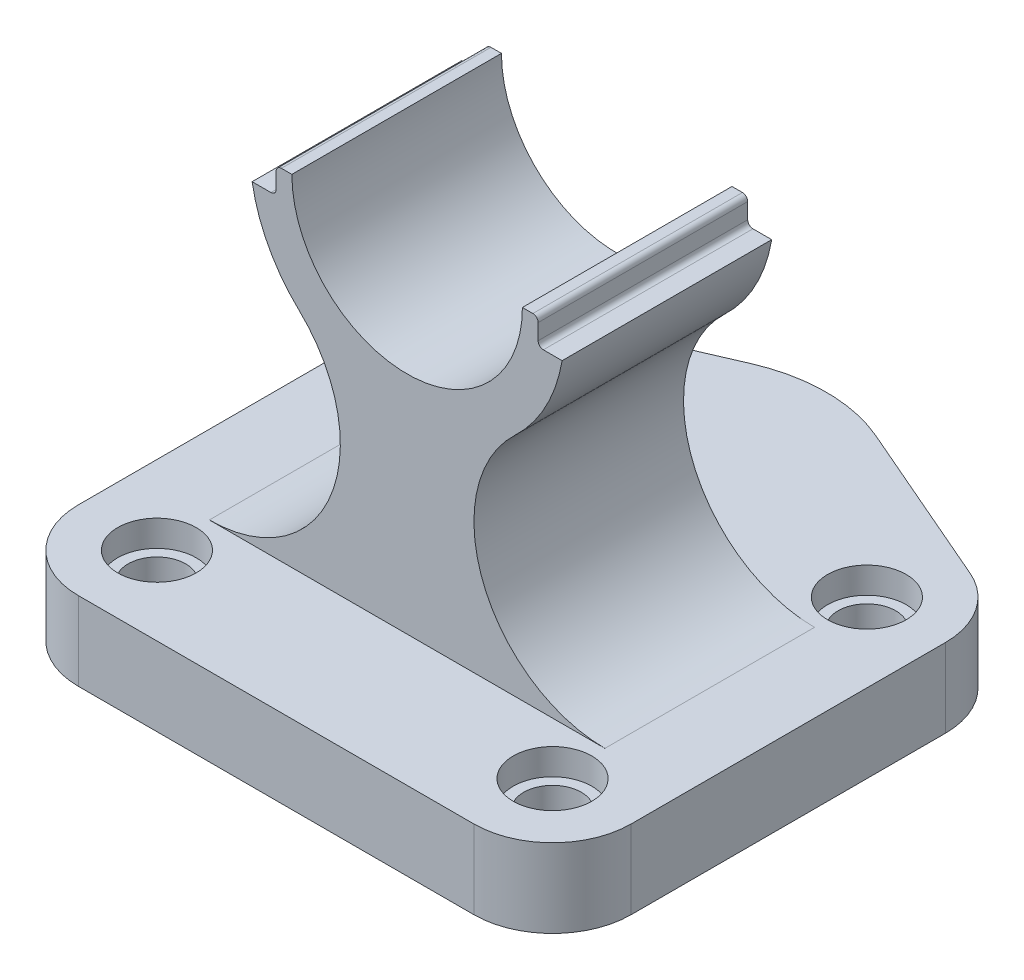
from build123d import *

# Parameters (mm, degrees)
BOSS_EXTRUDE1_DEPTH = 15
SKETCH1_5_R         = 7.5
CUT_EXTRUDE2_DEPTH  = 15
SKETCH1_6_R         = 7.5
SKETCH1_6_R_2       = 5.5
BOSS_EXTRUDE2_DEPTH = 10
BOSS_EXTRUDE3_DEPTH = 20


with BuildPart() as part:
    # Sketch1 → Boss-Extrude1 (new body)
    with BuildSketch(Plane(origin=(0, 0, 0), x_dir=(1, 0, 0), z_dir=(0, 1, 0))):
        with BuildLine():
            Line((52.75, -30), (52.75, 30))
            ThreePointArc((52.75, 30), (50.288021644, 38.233954897), (43.710264901, 43.765000629))
            Line((43.710264901, 43.765000629), (11.920529801, 57.530001258))
            ThreePointArc((11.920529801, 57.530001258), (0, 60), (-11.920529801, 57.530001258))
            Line((-11.920529801, 57.530001258), (-43.710264901, 43.765000629))
            ThreePointArc((-43.710264901, 43.765000629), (-50.288021644, 38.233954897), (-52.75, 30))
            Line((-52.75, 30), (-52.75, -30))
            ThreePointArc((-52.75, -30), (-48.356601718, -40.606601718), (-37.75, -45))
            Line((-37.75, -45), (37.75, -45))
            ThreePointArc((37.75, -45), (48.356601718, -40.606601718), (52.75, -30))
        make_face()
    extrude(amount=BOSS_EXTRUDE1_DEPTH)

    # Sketch1_5 → Cut-Extrude2 (cut)
    with BuildSketch(Plane(origin=(0, 0, 0), x_dir=(1, 0, 0), z_dir=(0, 1, 0))):
        with Locations((-37.75, 30)):
            Circle(SKETCH1_5_R)
        with Locations((37.75, 30)):
            Circle(SKETCH1_5_R)
        with Locations((37.75, -30)):
            Circle(SKETCH1_5_R)
        with Locations((-37.75, -30)):
            Circle(SKETCH1_5_R)
    extrude(amount=CUT_EXTRUDE2_DEPTH, mode=Mode.SUBTRACT)

    # Sketch1_6 → Boss-Extrude2 (add)
    # profile 1 of 4: a face of its own
    with BuildSketch(Plane(origin=(0, 0, 0), x_dir=(1, 0, 0), z_dir=(0, 1, 0))):
        with Locations((-37.75, 30)):
            Circle(SKETCH1_6_R)
        with Locations((-37.75, 30)):
            Circle(SKETCH1_6_R_2, mode=Mode.SUBTRACT)
    # profile 2 of 4: a face of its own
    with BuildSketch(Plane(origin=(0, 0, 0), x_dir=(1, 0, 0), z_dir=(0, 1, 0))):
        with Locations((37.75, 30)):
            Circle(SKETCH1_6_R)
        with Locations((37.75, 30)):
            Circle(SKETCH1_6_R_2, mode=Mode.SUBTRACT)
    # profile 3 of 4: a face of its own
    with BuildSketch(Plane(origin=(0, 0, 0), x_dir=(1, 0, 0), z_dir=(0, 1, 0))):
        with Locations((37.75, -30)):
            Circle(SKETCH1_6_R)
        with Locations((37.75, -30)):
            Circle(SKETCH1_6_R_2, mode=Mode.SUBTRACT)
    # profile 4 of 4: a face of its own
    with BuildSketch(Plane(origin=(0, 0, 0), x_dir=(1, 0, 0), z_dir=(0, 1, 0))):
        with Locations((-37.75, -30)):
            Circle(SKETCH1_6_R)
        with Locations((-37.75, -30)):
            Circle(SKETCH1_6_R_2, mode=Mode.SUBTRACT)
    extrude(amount=BOSS_EXTRUDE2_DEPTH)

    # Sketch2 → Boss-Extrude3 (add, symmetric)
    with BuildSketch(Plane.XY):
        with BuildLine():
            Line((-25, 79), (-25, 76))
            ThreePointArc((-25, 76), (-25.292893219, 75.292893219), (-26, 75))
            Line((-26, 75), (-29.580398915, 75))
            ThreePointArc((-29.580398915, 75), (-26.457352845, 65.85756455), (-20.590457551, 58.181818182))
            ThreePointArc((-20.590457551, 58.181818182), (-14.516162744, 30.768138177), (-37.749172176, 15))
            Line((-37.749172176, 15), (37.749172176, 15))
            ThreePointArc((37.749172176, 15), (14.516162744, 30.768138177), (20.590457551, 58.181818182))
            ThreePointArc((20.590457551, 58.181818182), (26.457352845, 65.85756455), (29.580398915, 75))
            Line((29.580398915, 75), (26, 75))
            ThreePointArc((26, 75), (25.292893219, 75.292893219), (25, 76))
            Line((25, 76), (25, 79))
            ThreePointArc((25, 79), (24.707106781, 79.707106781), (24, 80))
            Line((24, 80), (22, 80))
            ThreePointArc((22, 80), (0, 58), (-22, 80))
            Line((-22, 80), (-24, 80))
            ThreePointArc((-24, 80), (-24.707106781, 79.707106781), (-25, 79))
        make_face()
    extrude(amount=BOSS_EXTRUDE3_DEPTH, both=True)


solid = part.part
